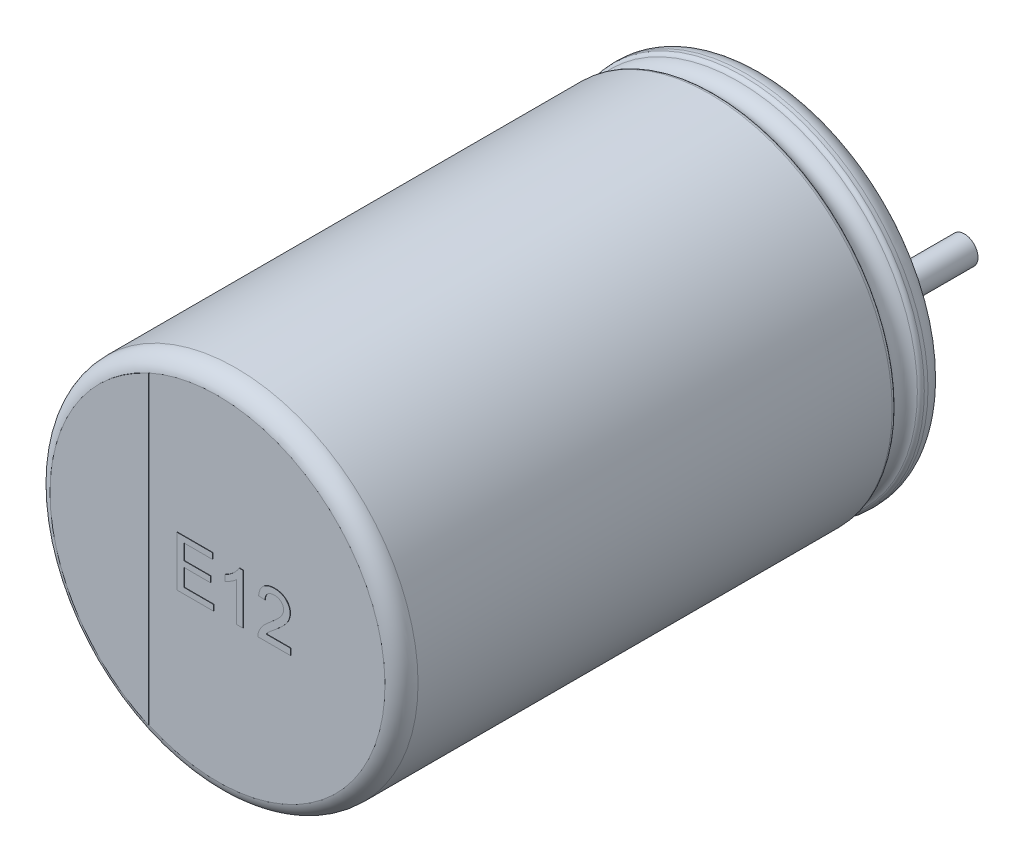
from build123d import *

# Parameters (mm, degrees)
SKETCH_2_R         = 0.3
EXTRUDE_1_DEPTH    = 2.7
EXTRUDE_2_DEPTH    = 0.01
EXTRUDE_1782_DEPTH = 0.01
EXTRUDE_5_DEPTH    = 0.05


with BuildPart() as part:
    # Sketch10 → Повернуть1 (revolve)
    with BuildSketch(Plane(origin=(0, 0, 0), x_dir=(0, 0, -1), z_dir=(1, 0, 0))):
        with BuildLine():
            Line((-12, 0), (-0.05, 0))
            Line((-0.05, 0), (-0.05, 3.403143426))
            ThreePointArc((-0.05, 3.403143426), (-0.052704561, 3.801565585), (-0.398206102, 4))
            Line((-0.398206102, 4), (-0.479422929, 4))
            ThreePointArc((-0.479422929, 4), (-0.534479696, 3.983479053), (-0.571344666, 3.939375046))
            ThreePointArc((-0.571344666, 3.939375046), (-0.831990181, 3.767472047), (-1.092635697, 3.939375046))
            ThreePointArc((-1.092635697, 3.939375046), (-1.129500666, 3.983479053), (-1.184557434, 4))
            Line((-1.184557434, 4), (-11.6, 4))
            ThreePointArc((-11.6, 4), (-11.85971595, 3.909961924), (-12, 3.67357323))
            Line((-12, 3.67357323), (-12, 0))
        make_face()
    revolve(axis=Axis((0, 0, -18.1630778), (0, 0, 1)))

    # Эскиз2 → Бобышка-Вытянуть1 (add)
    with BuildSketch(Plane(origin=(0, 0, 0.05), x_dir=(-1, 0, 0), z_dir=(0, 0, -1))):
        with Locations(Location((-1.75, 0, 0), (0, 0, 90))):
            Circle(SKETCH_2_R)
        with Locations(Location((1.75, 0, 0), (0, 0, 270))):
            Circle(SKETCH_2_R)
    extrude(amount=EXTRUDE_1_DEPTH)

    # Эскиз4 → Бобышка-Вытянуть2 (add)
    with BuildSketch(Plane.XY.offset(12)):
        with BuildLine():
            Line((-1.509635526, -3.349050739), (-1.509635526, 3.349050739))
            ThreePointArc((-1.509635526, 3.349050739), (-3.67357323, 0), (-1.509635526, -3.349050739))
        make_face()
    extrude(amount=EXTRUDE_2_DEPTH)

    # Эскиз5 → Extrude 1782 (add)
    with BuildSketch(Plane.XY.offset(12)):
        Polygon((-0.884369756, -0.464160183), (-0.884369756, 0.635839817), (-0.108728731, 0.635839817), (-0.108728731, 0.50891674), (-0.729241551, 0.50891674), (-0.729241551, 0.170455202), (-0.151036423, 0.170455202), (-0.151036423, 0.043532125), (-0.729241551, 0.043532125), (-0.729241551, -0.337237106), (-0.080523602, -0.337237106), (-0.080523602, -0.464160183), align=None)
        with BuildLine():
            Line((0.568194346, -0.464160183), (0.427168705, -0.464160183))
            Line((0.427168705, -0.464160183), (0.427168705, 0.393011291))
            add(Edge.make_bspline(
                [(0.427168705, 0.393011291), (0.419048436, 0.385180291), (0.402171347, 0.368904415), (0.373642411, 0.345869987), (0.341800473, 0.322523617), (0.30705902, 0.300073472), (0.271645985, 0.278939082), (0.237423847, 0.259931947), (0.204963957, 0.2438473), (0.183582453, 0.235052151), (0.173322551, 0.230831804)],
                knots=[0, 0, 0, 0, 0.893362401, 1.856755847, 2.901947673, 4.020460078, 5.132200827, 6.168787962, 7.121294059, 8, 8, 8, 8], degree=3))
            Line((0.173322551, 0.230831804), (0.173322551, 0.360839817))
            add(Edge.make_bspline(
                [(0.173322551, 0.360839817), (0.190944992, 0.369915409), (0.22567778, 0.387802865), (0.274747698, 0.418696959), (0.320559746, 0.452187428), (0.362355551, 0.488266859), (0.399822828, 0.525146514), (0.431397045, 0.562359534), (0.457816342, 0.598541851), (0.471071403, 0.623775005), (0.47740909, 0.635839817)],
                knots=[0, 0, 0, 0, 1.141258006, 2.249351951, 3.335817539, 4.406819942, 5.426913362, 6.360259544, 7.215985427, 8, 8, 8, 8], degree=3))
            Line((0.47740909, 0.635839817), (0.568194346, 0.635839817))
            Line((0.568194346, 0.635839817), (0.568194346, -0.464160183))
        make_face()
        with BuildLine():
            Line((1.61178409, -0.323134542), (1.61178409, -0.464160183))
            Line((1.61178409, -0.464160183), (0.892553321, -0.464160183))
            add(Edge.make_bspline(
                [(0.892553321, -0.464160183), (0.892538596, -0.455778633), (0.892509196, -0.439043625), (0.895341029, -0.41429361), (0.899776246, -0.389871925), (0.904791145, -0.37421127), (0.907316942, -0.366323644)],
                knots=[0, 0, 0, 0, 1.01057331, 2.01775941, 3.001627217, 4, 4, 4, 4], degree=3))
            add(Edge.make_bspline(
                [(0.907316942, -0.366323644), (0.911983776, -0.353436205), (0.921486217, -0.327195256), (0.940738263, -0.28933323), (0.963383218, -0.251700187), (0.98543127, -0.221061576), (1.005622524, -0.196583469), (1.022555522, -0.177432182), (1.041320388, -0.157828584), (1.061902095, -0.137776254), (1.084102555, -0.117145322), (1.107952062, -0.095866985), (1.133732239, -0.074337788), (1.151729501, -0.06006734), (1.160942744, -0.052761946)],
                knots=[0, 0, 0, 0, 1.204657718, 2.452881516, 3.728232997, 5.065887527, 5.768225529, 6.518857853, 7.313994055, 8.154655305, 9.046094665, 9.979688118, 10.965752482, 12, 12, 12, 12], degree=3))
            add(Edge.make_bspline(
                [(1.160942744, -0.052761946), (1.17509656, -0.040848908), (1.202350632, -0.017909599), (1.240837651, 0.01613021), (1.275989279, 0.047738101), (1.307245765, 0.077468067), (1.334862755, 0.105031746), (1.358905093, 0.130366688), (1.379579648, 0.15339383), (1.396634024, 0.174946656), (1.411023324, 0.195298518), (1.423216985, 0.215150503), (1.433378783, 0.234849381), (1.441842202, 0.254332819), (1.448536046, 0.273684139), (1.453098854, 0.292959718), (1.456193192, 0.311968296), (1.456502783, 0.324616814), (1.456655885, 0.330871868)],
                knots=[0, 0, 0, 0, 1.782554561, 3.432421876, 4.950675607, 6.337395053, 7.588547463, 8.709982106, 9.702713005, 10.569305638, 11.356701089, 12.103210377, 12.812277205, 13.490692607, 14.148717897, 14.782152033, 15.397739362, 16, 16, 16, 16], degree=3))
            add(Edge.make_bspline(
                [(1.456655885, 0.330871868), (1.456502765, 0.33705394), (1.456202352, 0.349182828), (1.453352046, 0.366933381), (1.449384192, 0.384027587), (1.44296938, 0.400157713), (1.435333823, 0.415801436), (1.425539378, 0.430464433), (1.414209218, 0.444512145), (1.401237145, 0.457574198), (1.387068602, 0.469828489), (1.371237275, 0.480014782), (1.354782961, 0.489185481), (1.337137999, 0.496559249), (1.318331062, 0.501973938), (1.298499055, 0.505903608), (1.277645126, 0.508395229), (1.263413785, 0.508740267), (1.256135051, 0.50891674)],
                knots=[0, 0, 0, 0, 0.988194508, 1.938783882, 2.870742509, 3.789494954, 4.709148727, 5.651055405, 6.603531303, 7.592354411, 8.592907906, 9.593461401, 10.59787167, 11.603930315, 12.645063138, 13.723588815, 14.835711238, 16, 16, 16, 16], degree=3))
            add(Edge.make_bspline(
                [(1.256135051, 0.50891674), (1.248488944, 0.508741141), (1.233524951, 0.508397482), (1.2116516, 0.505895924), (1.190886644, 0.502073881), (1.171279647, 0.496230304), (1.152854473, 0.488868832), (1.135686163, 0.4796027), (1.119499781, 0.469142913), (1.104805099, 0.456759313), (1.09151689, 0.443028428), (1.079720055, 0.428079647), (1.070054321, 0.411624491), (1.062071959, 0.39402477), (1.055653472, 0.37522516), (1.050993868, 0.355081939), (1.048453421, 0.333653269), (1.047942559, 0.318978922), (1.047681526, 0.311480843)],
                knots=[0, 0, 0, 0, 1.131143733, 2.213731411, 3.253917892, 4.251203413, 5.236093891, 6.184197493, 7.13373276, 8.082770301, 9.020476205, 9.957489029, 10.893177274, 11.836722509, 12.812818608, 13.827831385, 14.890097571, 16, 16, 16, 16], degree=3))
            Line((1.047681526, 0.311480843), (0.906655885, 0.325583407))
            add(Edge.make_bspline(
                [(0.906655885, 0.325583407), (0.908098777, 0.337874136), (0.910905801, 0.361784692), (0.917897713, 0.396415104), (0.927713726, 0.428631315), (0.939459413, 0.458882485), (0.954183739, 0.486653648), (0.970828321, 0.51251922), (0.990459839, 0.535658854), (1.012147457, 0.556801943), (1.036128788, 0.575434568), (1.062178564, 0.591712753), (1.090284868, 0.605328449), (1.12029116, 0.616601678), (1.152266325, 0.625154961), (1.18616513, 0.631288472), (1.222042089, 0.635069238), (1.246650532, 0.635579292), (1.259219987, 0.635839817)],
                knots=[0, 0, 0, 0, 1.130804643, 2.199883102, 3.223565206, 4.205909148, 5.160801384, 6.091796021, 7.01151579, 7.927798993, 8.855738875, 9.7815393, 10.730299821, 11.705391175, 12.706931101, 13.751121791, 14.851322166, 16, 16, 16, 16], degree=3))
            add(Edge.make_bspline(
                [(1.259219987, 0.635839817), (1.271939892, 0.635622003), (1.29671834, 0.6351977), (1.332824523, 0.63085623), (1.366891704, 0.624094431), (1.399044773, 0.614670552), (1.429093765, 0.602313037), (1.457061794, 0.587214944), (1.483077817, 0.56952355), (1.506707157, 0.549026482), (1.528014351, 0.526650499), (1.546686965, 0.502770502), (1.562298168, 0.477488506), (1.575590139, 0.451149122), (1.585449285, 0.423195817), (1.592382417, 0.39400862), (1.597093682, 0.363562591), (1.597482973, 0.342789196), (1.597681526, 0.332193984)],
                knots=[0, 0, 0, 0, 1.195390245, 2.328627238, 3.413424916, 4.457841177, 5.473507151, 6.462241215, 7.441013641, 8.425227782, 9.397253344, 10.342087291, 11.269524934, 12.186751184, 13.110685745, 14.048630397, 15.004728144, 16, 16, 16, 16], degree=3))
            add(Edge.make_bspline(
                [(1.597681526, 0.332193984), (1.597378339, 0.321308604), (1.596771295, 0.299513821), (1.592033242, 0.266937048), (1.58392638, 0.234713806), (1.573178844, 0.202451918), (1.558495473, 0.170023339), (1.539945527, 0.136980714), (1.516932293, 0.103201988), (1.494800013, 0.074486318), (1.474198453, 0.050415346), (1.455937117, 0.030603529), (1.434809808, 0.009554798), (1.411609091, -0.013459812), (1.385388728, -0.037623466), (1.356902093, -0.063659758), (1.325525598, -0.090883511), (1.303744195, -0.109481472), (1.292493225, -0.119088068)],
                knots=[0, 0, 0, 0, 0.927118007, 1.856282007, 2.79721255, 3.754929441, 4.749232485, 5.824981375, 6.979078785, 8.228161913, 8.911614355, 9.677694854, 10.522803217, 11.452009355, 12.461436787, 13.560019032, 14.739651695, 16, 16, 16, 16], degree=3))
            add(Edge.make_bspline(
                [(1.292493225, -0.119088068), (1.282858468, -0.126931787), (1.26448647, -0.141888552), (1.238348743, -0.163571774), (1.21493729, -0.183454702), (1.193704637, -0.200888792), (1.175424065, -0.216717308), (1.159451664, -0.230247031), (1.146367722, -0.24215823), (1.126443194, -0.260251582), (1.101207079, -0.286041826), (1.082612031, -0.311101486), (1.073683128, -0.323134542)],
                knots=[0, 0, 0, 0, 1.241996727, 2.368296581, 3.394949853, 4.3125351, 5.114548721, 5.812230366, 6.404953749, 6.883082049, 8.503329734, 10, 10, 10, 10], degree=3))
            Line((1.073683128, -0.323134542), (1.61178409, -0.323134542))
        make_face()
    extrude(amount=EXTRUDE_1782_DEPTH)

    # Эскиз6 → Бобышка-Вытянуть5 (add)
    with BuildSketch(Plane(origin=(0, 0, 0.05), x_dir=(-1, 0, 0), z_dir=(0, 0, -1))):
        with BuildLine():
            Line((-1.75, 0.465643654), (-2.133155916, 0.465643654))
            ThreePointArc((-2.133155916, 0.465643654), (-2.336107869, 0.569662474), (-2.37017324, 0.795159615))
            ThreePointArc((-2.37017324, 0.795159615), (0, 2.5), (2.37017324, 0.795159615))
            ThreePointArc((2.37017324, 0.795159615), (2.336107869, 0.569662474), (2.133155916, 0.465643654))
            Line((2.133155916, 0.465643654), (1.75, 0.465643654))
            ThreePointArc((1.75, 0.465643654), (1.284356346, 0), (1.75, -0.465643654))
            Line((1.75, -0.465643654), (2.133155916, -0.465643654))
            ThreePointArc((2.133155916, -0.465643654), (2.336107869, -0.569662474), (2.37017324, -0.795159615))
            ThreePointArc((2.37017324, -0.795159615), (0, -2.5), (-2.37017324, -0.795159615))
            ThreePointArc((-2.37017324, -0.795159615), (-2.336107869, -0.569662474), (-2.133155916, -0.465643654))
            Line((-2.133155916, -0.465643654), (-1.75, -0.465643654))
            ThreePointArc((-1.75, -0.465643654), (-1.284356346, 0), (-1.75, 0.465643654))
        make_face()
    extrude(amount=EXTRUDE_5_DEPTH)


solid = part.part
